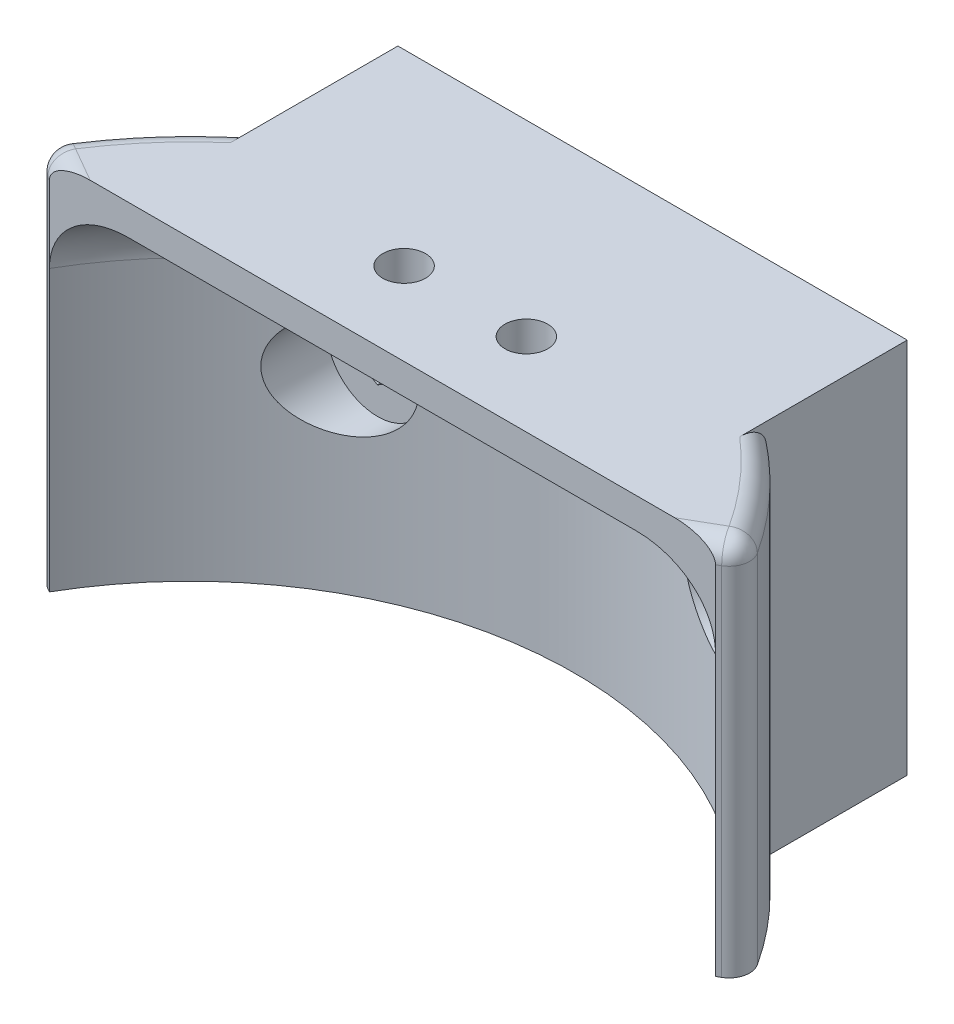
from build123d import *

# Parameters (mm, degrees)
BOSS_EXTRUDE2_DEPTH = 37
BOSS_EXTRUDE4_DEPTH = 3
FILLET1_R           = 6.5
SKETCH5_R           = 2.1
CUT_EXTRUDE1_DEPTH  = 5
SKETCH6_W           = 50
SKETCH6_H           = 37
SKETCH6_W_2         = 46.2
SKETCH6_H_2         = 33.5
BOSS_EXTRUDE5_DEPTH = 5
SKETCH7_R           = 1.1
CUT_EXTRUDE2_DEPTH  = 1
CUT_EXTRUDE3_DEPTH  = 3
SKETCH9_R           = 5
CUT_EXTRUDE4_DEPTH  = 18.515687401
FILLET2_R           = 2


with BuildPart() as part:
    # Sketch2 → Boss-Extrude2 (new body)
    with BuildSketch(Plane(origin=(0, 0, 0), x_dir=(1, 0, 0), z_dir=(0, 1, 0))):
        with BuildLine():
            Line((32.692458993, 18.875), (34.857522502, 20.125))
            ThreePointArc((34.857522502, 20.125), (30.468551498, 26.300757966), (25, 31.544611267))
            Line((25, 31.544611267), (25, 40.390687301))
            Line((25, 40.390687301), (-25, 40.390687301))
            Line((-25, 40.390687301), (-25, 31.544611267))
            ThreePointArc((-25, 31.544611267), (-30.468551498, 26.300757966), (-34.857522502, 20.125))
            Line((-34.857522502, 20.125), (-32.692458993, 18.875))
            ThreePointArc((-32.692458993, 18.875), (0, 37.75), (32.692458993, 18.875))
        make_face()
    extrude(amount=BOSS_EXTRUDE2_DEPTH)

    # Sketch4 → Boss-Extrude4 (add)
    with BuildSketch(Plane(origin=(0, 37, 0), x_dir=(1, 0, 0), z_dir=(0, 1, 0))):
        with BuildLine():
            Line((-32.692458993, 18.875), (32.692458993, 18.875))
            Line((32.692458993, 18.875), (34.857522502, 20.125))
            ThreePointArc((34.857522502, 20.125), (0, 40.25), (-34.857522502, 20.125))
            Line((-34.857522502, 20.125), (-32.692458993, 18.875))
        make_face()
    extrude(amount=-BOSS_EXTRUDE4_DEPTH)

    # Fillet1
    fillet1_edges = [part.edges().sort_by_distance(p)[0] for p in [
        (0, 34, -37.75),
    ]]
    fillet(fillet1_edges, radius=FILLET1_R)

    # Sketch5 → Cut-Extrude1 (cut)
    with BuildSketch(Plane(origin=(0, 34, 0), x_dir=(-1, 0, 0), z_dir=(0, -1, 0))):
        with Locations((-6, 27)):
            Circle(SKETCH5_R)
        with Locations((6, 27)):
            Circle(SKETCH5_R)
    extrude(amount=-CUT_EXTRUDE1_DEPTH, mode=Mode.SUBTRACT)

    # Sketch6 → Boss-Extrude5 (add)
    with BuildSketch(Plane(origin=(0, 0, -40.390687301), x_dir=(-1, 0, 0), z_dir=(0, 0, -1))):
        with Locations((0, 18.5)):
            Rectangle(SKETCH6_W, SKETCH6_H)
        with Locations((0, 18.5)):
            Rectangle(SKETCH6_W_2, SKETCH6_H_2, mode=Mode.SUBTRACT)
    extrude(amount=BOSS_EXTRUDE5_DEPTH)

    # Sketch7 → Cut-Extrude2 (cut)
    with BuildSketch(Plane(origin=(0, 0, -40.390687301), x_dir=(-1, 0, 0), z_dir=(0, 0, -1))):
        with Locations((-18, 18.5)):
            Circle(SKETCH7_R)
        with Locations((18, 18.5)):
            Circle(SKETCH7_R)
    extrude(amount=-CUT_EXTRUDE2_DEPTH, mode=Mode.SUBTRACT)

    # Sketch8 → Cut-Extrude3 (cut)
    with BuildSketch(Plane(origin=(0, 0, -39.390687301), x_dir=(-1, 0, 0), z_dir=(0, 0, -1))):
        Polygon((-16, 17.345299462), (-16, 19.654700538), (-18, 20.809401077), (-20, 19.654700538), (-20, 17.345299462), (-18, 16.190598923), align=None)
        Polygon((20, 17.345299462), (20, 19.654700538), (18, 20.809401077), (16, 19.654700538), (16, 17.345299462), (18, 16.190598923), align=None)
    extrude(amount=-CUT_EXTRUDE3_DEPTH, mode=Mode.SUBTRACT)

    # Sketch9 → Cut-Extrude4 (cut, through all)
    with BuildSketch(Plane(origin=(0, 0, -36.390687301), x_dir=(-1, 0, 0), z_dir=(0, 0, -1))):
        with Locations((-18, 18.5)):
            Circle(SKETCH9_R)
        with Locations((18, 18.5)):
            Circle(SKETCH9_R)
    extrude(amount=-CUT_EXTRUDE4_DEPTH, mode=Mode.SUBTRACT)

    # Fillet2
    fillet2_edges = [part.edges().sort_by_distance(p)[0] for p in [
        (34.857522502, 18.5, -20.125),
        (-34.857522502, 18.5, -20.125),
        (-30.468551498, 37, -26.300757966),
        (-33.774990748, 37, -19.5),
        (33.774990748, 37, -19.5),
        (30.468551498, 37, -26.300757966),
    ]]
    fillet(fillet2_edges, radius=FILLET2_R)


solid = part.part
